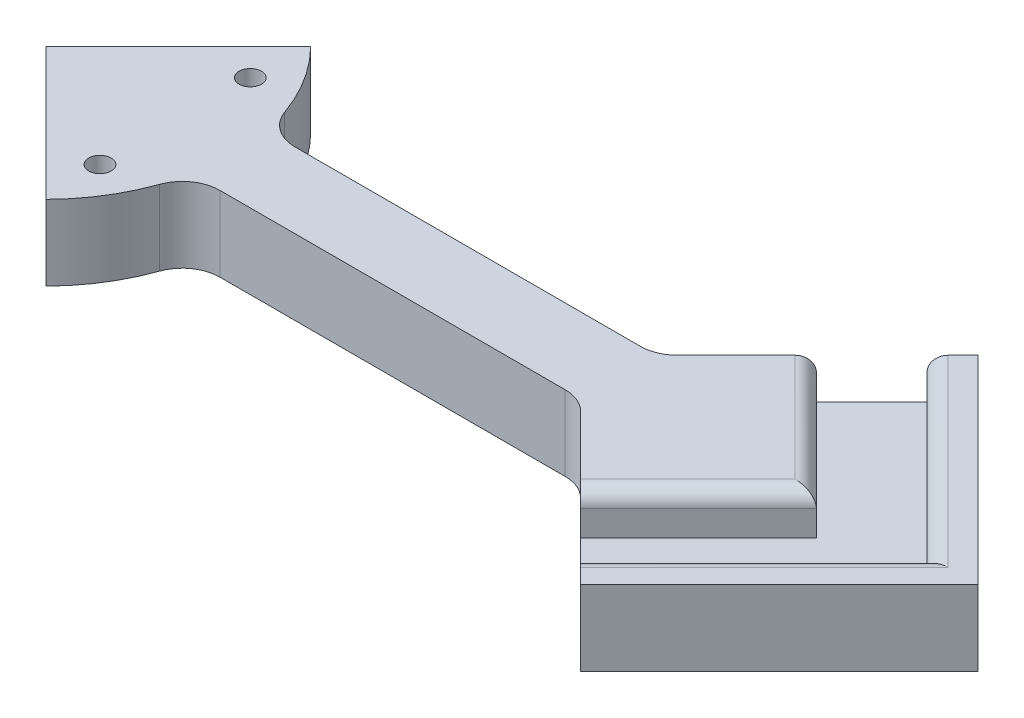
from build123d import *

# Parameters (mm, degrees)
BOSS_EXTRUDE11_DEPTH = 12.7
BOSS_EXTRUDE12_DEPTH = 12.7
BOSS_EXTRUDE13_DEPTH = 12.7
CUT_EXTRUDE1_START   = 12.7
CUT_EXTRUDE1_DEPTH   = 6.858
SKETCH25_R           = 1.90000001
CUT_EXTRUDE2_DEPTH   = 13.7
FILLET1_R            = 2.54
FILLET2_R            = 6.35


with BuildPart() as part:
    # Sketch12 → Boss-Extrude11 (new body)
    with BuildSketch(Plane(origin=(0, 0, 0), x_dir=(1, 0, 0), z_dir=(0, 1, 0))):
        Polygon((139.879605122, 6.35), (6.529605122, 6.35), (0.179605122, 0), (6.529605122, -6.35), (139.879605122, -6.35), align=None)
    extrude(amount=BOSS_EXTRUDE11_DEPTH)

    # Sketch23 → Boss-Extrude12 (add)
    with BuildSketch(Plane(origin=(0, 0, 0), x_dir=(1, 0, 0), z_dir=(0, 1, 0))):
        Polygon((90.5209817, 0), (124.090746971, 33.569765271), (157.660512242, 0), (124.090746971, -33.569765271), align=None)
    extrude(amount=BOSS_EXTRUDE12_DEPTH)

    # Sketch26 → Boss-Extrude13 (add)
    with BuildSketch(Plane(origin=(0, 0, 0), x_dir=(1, 0, 0), z_dir=(0, 1, 0))):
        with BuildLine():
            Line((22.540263258, 22.360658136), (0.179605122, 0))
            Line((0.179605122, 0), (22.540263258, -22.360658136))
            ThreePointArc((22.540263258, -22.360658136), (31.75, 0), (22.540263258, 22.360658136))
        make_face()
    extrude(amount=BOSS_EXTRUDE13_DEPTH)

    # Sketch24 → Cut-Extrude1 (cut)
    with BuildSketch(Plane(origin=(0, 0, 0), x_dir=(1, 0, 0), z_dir=(0, 1, 0)).offset(CUT_EXTRUDE1_START)):
        Polygon((119.780224033, 29.259242333), (149.039466366, 0), (119.780224033, -29.259242333), (110.440757667, -19.919775967), (130.360533634, 0), (110.440757667, 19.919775967), align=None)
    extrude(amount=-CUT_EXTRUDE1_DEPTH, mode=Mode.SUBTRACT)

    # Sketch25 → Cut-Extrude2 (cut, through all)
    with BuildSketch(Plane(origin=(0, 0, 0), x_dir=(1, 0, 0), z_dir=(0, 1, 0))):
        with Locations((21.997045256, 12.7)):
            Circle(SKETCH25_R)
        with Locations((21.997045256, -12.7)):
            Circle(SKETCH25_R)
    extrude(amount=CUT_EXTRUDE2_DEPTH, mode=Mode.SUBTRACT)

    # Fillet1
    fillet1_edges = [part.edges().sort_by_distance(p)[0] for p in [
        (120.400645651, 12.7, 9.959887983),
        (120.400645651, 12.7, -9.959887983),
        (134.4098452, 12.7, -14.629621166),
        (134.4098452, 12.7, 14.629621166),
    ]]
    fillet(fillet1_edges, radius=FILLET1_R)

    # Fillet2
    fillet2_edges = [part.edges().sort_by_distance(p)[0] for p in [
        (96.8709817, 6.35, 6.35),
        (96.8709817, 6.35, -6.35),
        (31.108519733, 6.35, -6.35),
        (31.108519733, 6.35, 6.35),
    ]]
    fillet(fillet2_edges, radius=FILLET2_R)


solid = part.part
